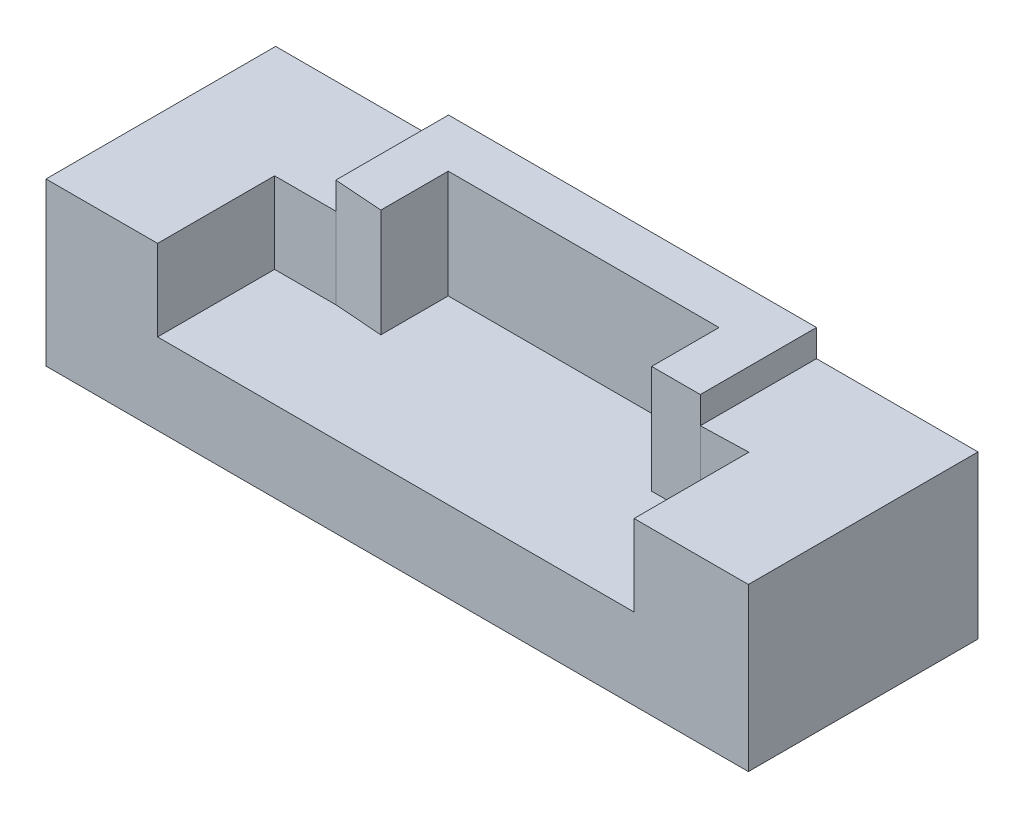
from build123d import *

# Parameters (mm, degrees)
SKETCH1_W           = 52
SKETCH1_H           = 17
BOSS_EXTRUDE1_DEPTH = 6
BOSS_EXTRUDE2_DEPTH = 6
BOSS_EXTRUDE4_DEPTH = 8
BOSS_EXTRUDE5_DEPTH = 6


with BuildPart() as part:
    # Sketch1 → Boss-Extrude1 (new body)
    with BuildSketch(Plane(origin=(0, 0, 0), x_dir=(1, 0, 0), z_dir=(0, 1, 0))):
        with Locations((-13.173913043, 3.202898551)):
            Rectangle(SKETCH1_W, SKETCH1_H)
    extrude(amount=BOSS_EXTRUDE1_DEPTH)

    # Sketch2 → Boss-Extrude2 (add)
    with BuildSketch(Plane(origin=(0, 6, 0), x_dir=(1, 0, 0), z_dir=(0, 1, 0))):
        Polygon((-39.173913043, 11.702898551), (-26.373913043, 11.702898551), (-26.373913043, 3.365569346), (-30.913828569, 3.365569346), (-30.913828569, -5.297101449), (-39.173913043, -5.297101449), align=None)
    extrude(amount=BOSS_EXTRUDE2_DEPTH)

    # Sketch3 → Boss-Extrude4 (add)
    with BuildSketch(Plane(origin=(0, 6, 0), x_dir=(1, 0, 0), z_dir=(0, 1, 0))):
        Polygon((0.870186747, 11.702898551), (-26.373913043, 11.702898551), (-26.373913043, 3.365569346), (-22.783033953, 3.101787471), (-22.783033953, 8.091138713), (-2.733233594, 8.091138713), (-2.733233594, 3.101787471), (0.870186747, 3.101787471), align=None)
    extrude(amount=BOSS_EXTRUDE4_DEPTH)

    # Sketch4 → Boss-Extrude5 (add)
    with BuildSketch(Plane(origin=(0, 6, 0), x_dir=(1, 0, 0), z_dir=(0, 1, 0))):
        Polygon((0.870186747, 11.702898551), (12.826086957, 11.702898551), (12.826086957, -5.297101449), (4.364373788, -5.297101449), (4.364373788, 3.202898551), (0.870186747, 3.101787471), align=None)
    extrude(amount=BOSS_EXTRUDE5_DEPTH)


solid = part.part
